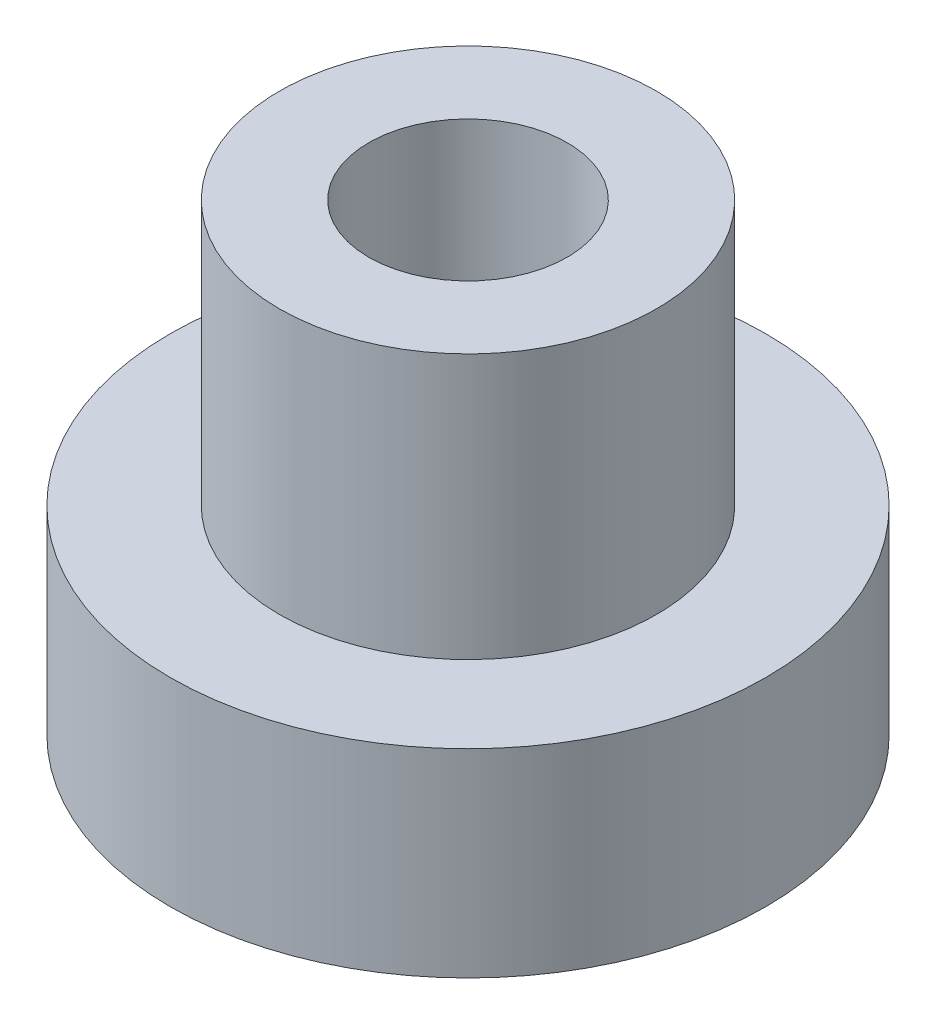
from build123d import *

# Parameters (mm, degrees)
SKETCH1_R           = 4.5
SKETCH1_R_2         = 1.5
BOSS_EXTRUDE1_DEPTH = 3
SKETCH2_R           = 2.85
SKETCH2_R_2         = 1.5
BOSS_EXTRUDE2_DEPTH = 4


with BuildPart() as part:
    # Sketch1 → Boss-Extrude1 (new body)
    with BuildSketch(Plane(origin=(0, 0, 0), x_dir=(1, 0, 0), z_dir=(0, 1, 0))):
        Circle(SKETCH1_R)
        Circle(SKETCH1_R_2, mode=Mode.SUBTRACT)
    extrude(amount=BOSS_EXTRUDE1_DEPTH)

    # Sketch2 → Boss-Extrude2 (add)
    with BuildSketch(Plane(origin=(0, 3, 0), x_dir=(1, 0, 0), z_dir=(0, 1, 0))):
        Circle(SKETCH2_R)
        Circle(SKETCH2_R_2, mode=Mode.SUBTRACT)
    extrude(amount=BOSS_EXTRUDE2_DEPTH)


solid = part.part
